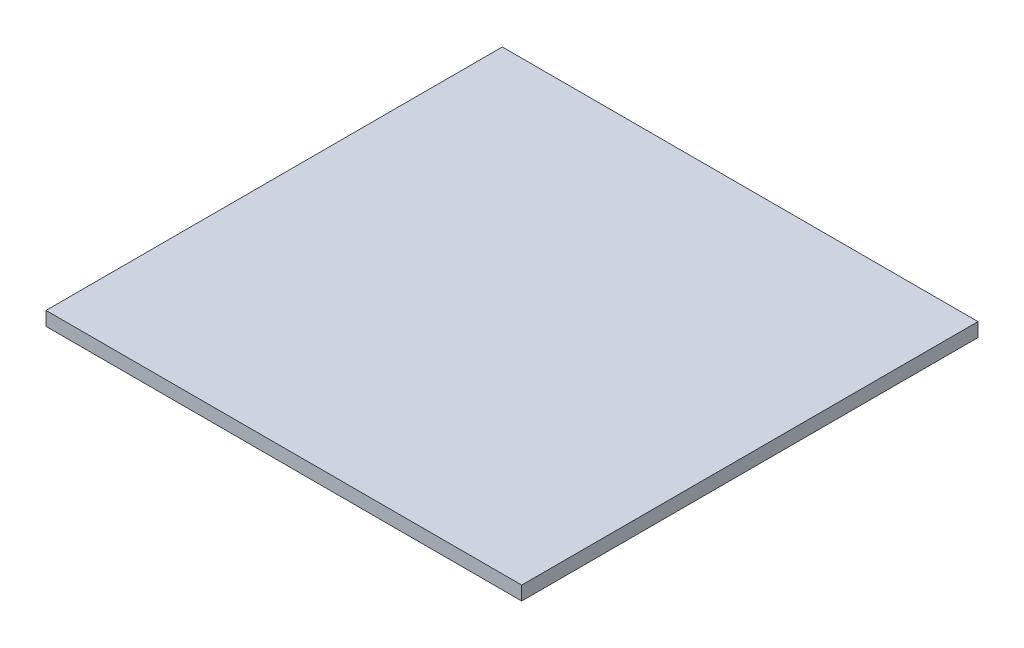
from build123d import *

# Parameters (mm, degrees)
SKETCH1_W           = 103
SKETCH1_H           = 98.8
BOSS_EXTRUDE1_DEPTH = 3


with BuildPart() as part:
    # Sketch1 → Boss-Extrude1 (new body)
    with BuildSketch(Plane(origin=(0, 0, 0), x_dir=(1, 0, 0), z_dir=(0, 1, 0))):
        with Locations((7.218457944, -28.701985981)):
            Rectangle(SKETCH1_W, SKETCH1_H)
    extrude(amount=BOSS_EXTRUDE1_DEPTH)


solid = part.part
